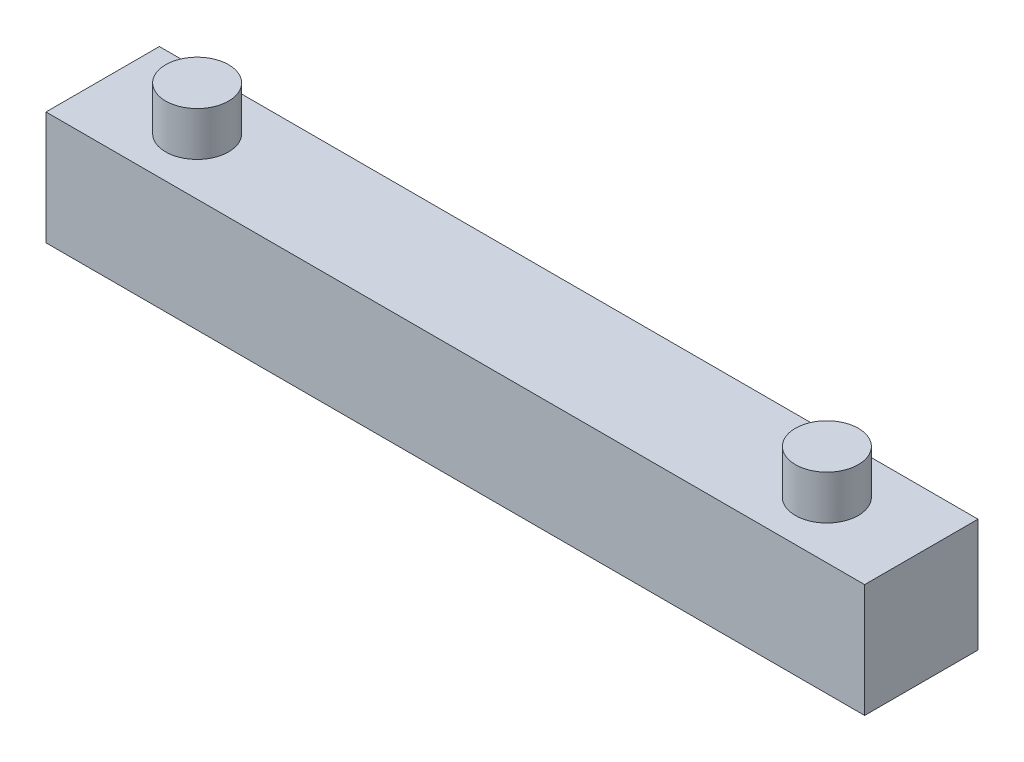
from build123d import *

# Parameters (mm, degrees)
SKETCH1_W           = 65
SKETCH1_H           = 9
BOSS_EXTRUDE1_DEPTH = 9
SKETCH2_R           = 2.5
BOSS_EXTRUDE2_DEPTH = 3.5


with BuildPart() as part:
    # Sketch1 → Boss-Extrude1 (new body)
    with BuildSketch(Plane.XY):
        with Locations((32.5, 4.5)):
            Rectangle(SKETCH1_W, SKETCH1_H)
    extrude(amount=BOSS_EXTRUDE1_DEPTH)

    # Sketch2 → Boss-Extrude2 (add)
    with BuildSketch(Plane(origin=(0, 9, 0), x_dir=(1, 0, 0), z_dir=(0, 1, 0))):
        with Locations((57.5, -4.5)):
            Circle(SKETCH2_R)
        with Locations((7.5, -4.5)):
            Circle(SKETCH2_R)
    extrude(amount=BOSS_EXTRUDE2_DEPTH)


solid = part.part
